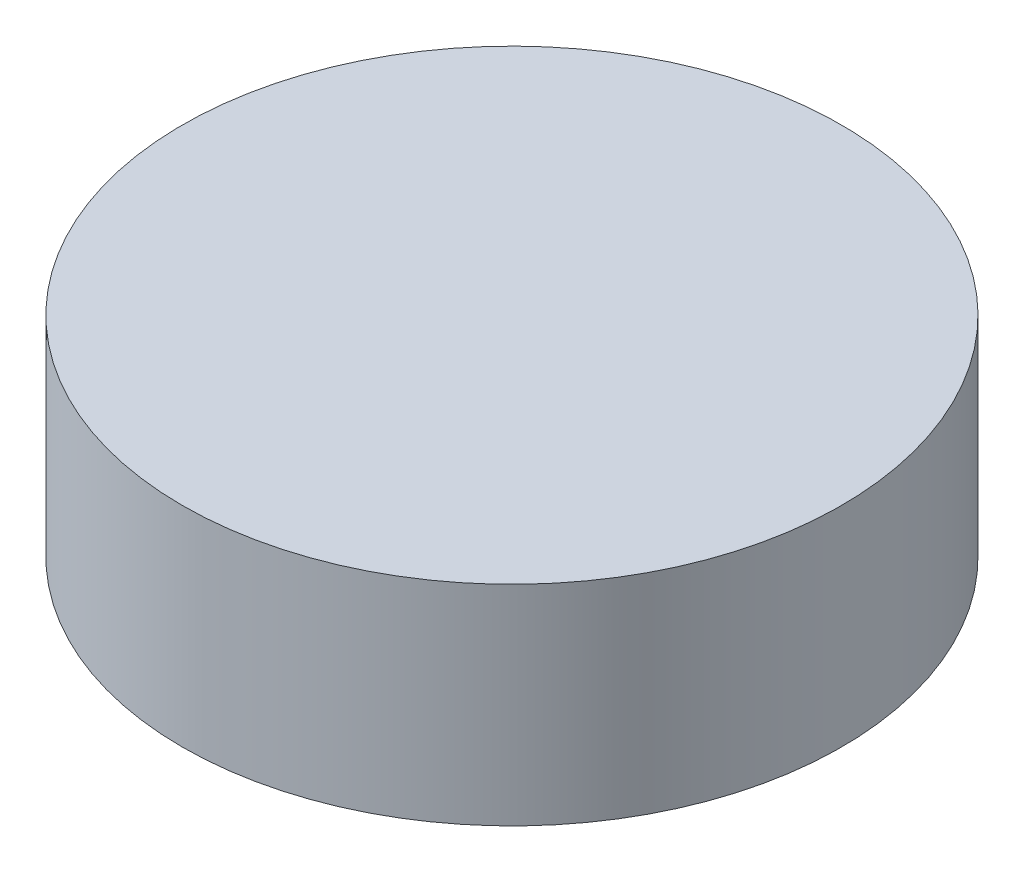
from build123d import *

# Parameters (mm, degrees)
SKETCH1_R           = 5
BOSS_EXTRUDE1_DEPTH = 3.175


with BuildPart() as part:
    # Sketch1 → Boss-Extrude1 (new body)
    with BuildSketch(Plane(origin=(0, 0, 0), x_dir=(1, 0, 0), z_dir=(0, 1, 0))):
        Circle(SKETCH1_R)
    extrude(amount=BOSS_EXTRUDE1_DEPTH)


solid = part.part
